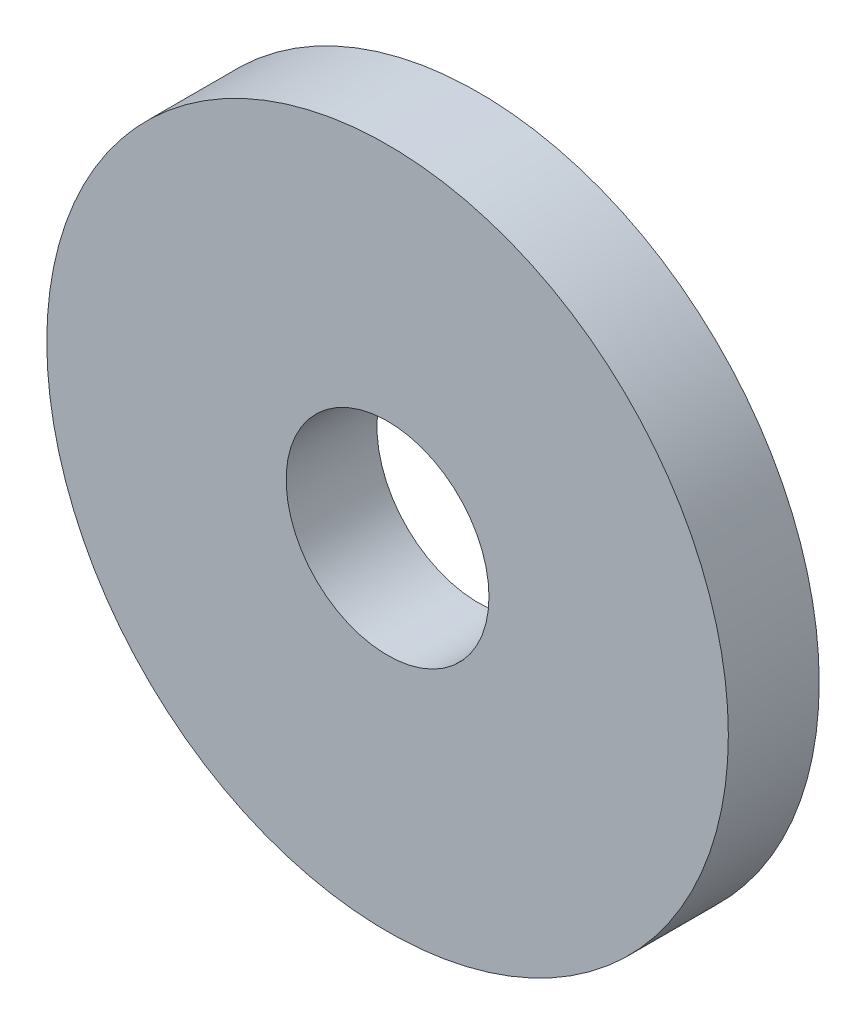
from build123d import *

# Parameters (mm, degrees)
SKETCH1_R           = 16.002
SKETCH1_R_2         = 4.7625
BOSS_EXTRUDE1_DEPTH = 2.1336


with BuildPart() as part:
    # Sketch1 → Boss-Extrude1 (new body, symmetric)
    with BuildSketch(Plane.XY):
        Circle(SKETCH1_R)
        Circle(SKETCH1_R_2, mode=Mode.SUBTRACT)
    extrude(amount=BOSS_EXTRUDE1_DEPTH, both=True)


solid = part.part
